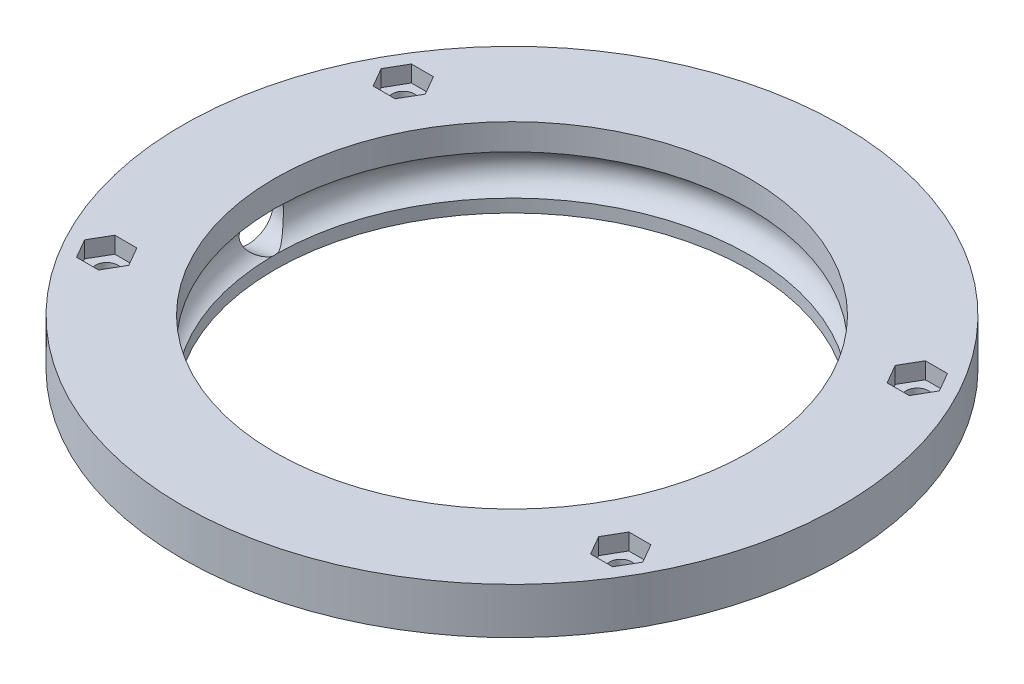
from build123d import *

# Parameters (mm, degrees)
CROQUIS4_R            = 1.7
CORTAR_EXTRUIR1_DEPTH = 10
CORTAR_EXTRUIR2_DEPTH = 2.5


with BuildPart() as part:
    # Croquis1 → Revolución1 (revolve)
    with BuildSketch(Plane.XY):
        with BuildLine():
            Line((50, 12), (36, 12))
            Line((36, 12), (36, 8.039736831))
            ThreePointArc((36, 8.039736831), (38.2, 5), (36, 1.960263169))
            Line((36, 1.960263169), (36, 0))
            Line((36, 0), (40, 0))
            Line((40, 0), (40, 5))
            Line((40, 5), (50, 5))
            Line((50, 5), (50, 12))
        make_face()
    revolve(axis=Axis((0, 9.671658493, 0), (0, -1, 0)))

    # Croquis2 → Cortar-Revolución1 (revolve, cut)
    with BuildSketch(Plane(origin=(0, 5, 0), x_dir=(1, 0, 0), z_dir=(0, 1, 0))):
        Polygon((-35.5, 0), (-51.5, 0), (-51.5, 3.7), (-40.5, 3.7), (-35.5, 3), align=None)
    revolve(axis=Axis((-54.955446394, 5, 0), (1, 0, 0)), mode=Mode.SUBTRACT)

    # Croquis4 → Cortar-Extruir1 (cut)
    with BuildSketch(Plane(origin=(0, 12, 0), x_dir=(1, 0, 0), z_dir=(0, 1, 0))):
        with Locations((-39, 22.5)):
            Circle(CROQUIS4_R)
        with Locations((39, 22.5)):
            Circle(CROQUIS4_R)
        with Locations((39, -22.5)):
            Circle(CROQUIS4_R)
        with Locations((-39, -22.5)):
            Circle(CROQUIS4_R)
    extrude(amount=-CORTAR_EXTRUIR1_DEPTH, mode=Mode.SUBTRACT)

    # Croquis5 → Cortar-Extruir2 (cut)
    with BuildSketch(Plane(origin=(0, 12, 0), x_dir=(1, 0, 0), z_dir=(0, 1, 0))):
        Polygon((-42.35, 22.5), (-40.675, 19.598814897), (-37.325, 19.598814897), (-35.65, 22.5), (-37.325, 25.401185103), (-40.675, 25.401185103), align=None)
        Polygon((-42.35, -22.5), (-40.675, -25.401185103), (-37.325, -25.401185103), (-35.65, -22.5), (-37.325, -19.598814897), (-40.675, -19.598814897), align=None)
        Polygon((35.65, 22.5), (37.325, 19.598814897), (40.675, 19.598814897), (42.35, 22.5), (40.675, 25.401185103), (37.325, 25.401185103), align=None)
        Polygon((35.65, -22.5), (37.325, -25.401185103), (40.675, -25.401185103), (42.35, -22.5), (40.675, -19.598814897), (37.325, -19.598814897), align=None)
    extrude(amount=-CORTAR_EXTRUIR2_DEPTH, mode=Mode.SUBTRACT)


solid = part.part
